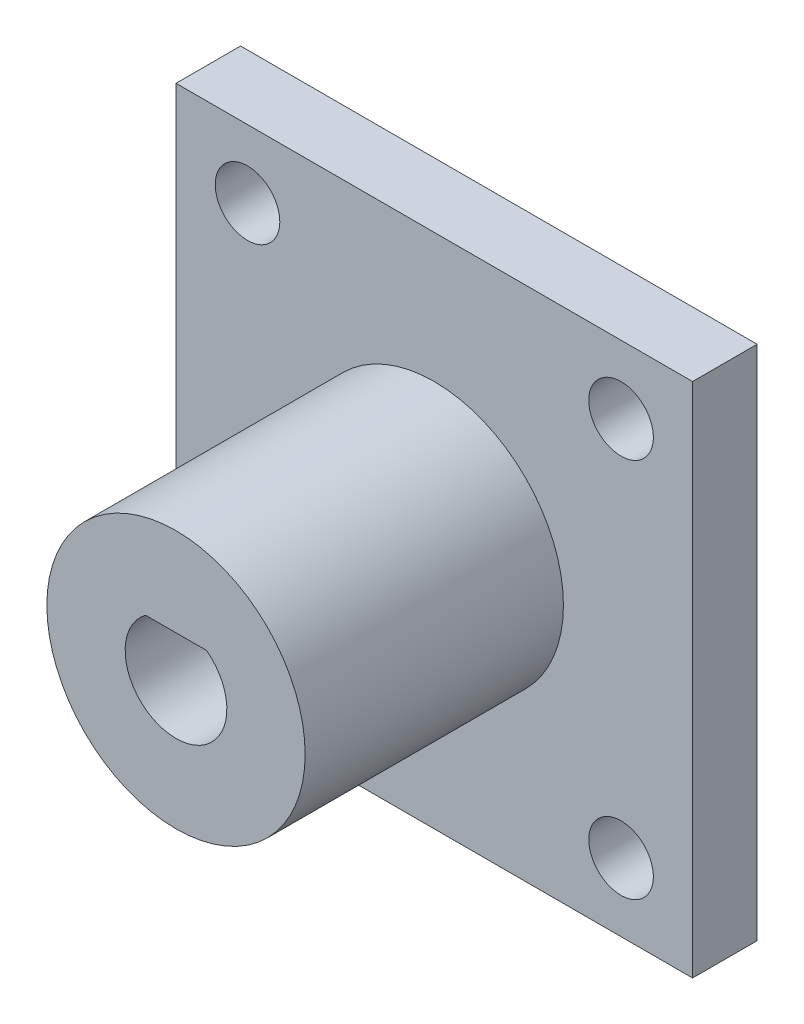
from build123d import *

# Parameters (mm, degrees)
SKETCH1_R               = 12.7
BOSS_EXTRUDE5_DEPTH     = 31.75
SKETCH3_W               = 50.8
SKETCH3_H               = 50.8
BOSS_EXTRUDE6_DEPTH     = 6.35
SKETCH4_R               = 3.175
CUT_EXTRUDE1_DEPTH      = 32.75
MIRROR2_COPY_1_SKETCH_R = 3.175
MIRROR2_COPY_1_DEPTH    = 32.75


with BuildPart() as part:
    # Sketch1 → Boss-Extrude5 (new body)
    with BuildSketch(Plane.XY):
        Circle(SKETCH1_R)
        with BuildLine():
            Line((-3.000000011, 3.999999874), (3.000000011, 3.999999874))
            ThreePointArc((3.000000011, 3.999999874), (0, -4.999999906), (-3.000000011, 3.999999874))
        make_face(mode=Mode.SUBTRACT)
    extrude(amount=BOSS_EXTRUDE5_DEPTH)


with BuildPart() as body_2:
    # Sketch3 → Boss-Extrude6 (new body)
    with BuildSketch(Plane.XY):
        Rectangle(SKETCH3_W, SKETCH3_H)
    extrude(amount=BOSS_EXTRUDE6_DEPTH)

    # Sketch4 → Cut-Extrude1 (cut, through all)
    with BuildSketch(Plane(origin=(0, 0, 0), x_dir=(-1, 0, 0), z_dir=(0, 0, -1))):
        with Locations((-18.366924537, 18.704816802)):
            Circle(SKETCH4_R)
    cut_extrude1 = extrude(amount=-CUT_EXTRUDE1_DEPTH, mode=Mode.SUBTRACT)

    # Mirror1: Cut-Extrude1 across plane
    add(cut_extrude1.mirror(Plane(origin=(0, 0, 0), x_dir=(0, 0, 1), z_dir=(1, 0, 0))), mode=Mode.SUBTRACT)

    # Mirror2: Cut-Extrude1 across plane
    add(cut_extrude1.mirror(Plane.ZX), mode=Mode.SUBTRACT)

    # Mirror2 copy 1 sketch → Mirror2 copy 1 (cut, through all)
    with BuildSketch(Plane(origin=(0, 0, 0), x_dir=(1, 0, 0), z_dir=(0, 0, -1))):
        with Locations((-18.366924537, 18.704816802)):
            Circle(MIRROR2_COPY_1_SKETCH_R)
    extrude(amount=-MIRROR2_COPY_1_DEPTH, mode=Mode.SUBTRACT)


solid = Compound([part.part, body_2.part])
